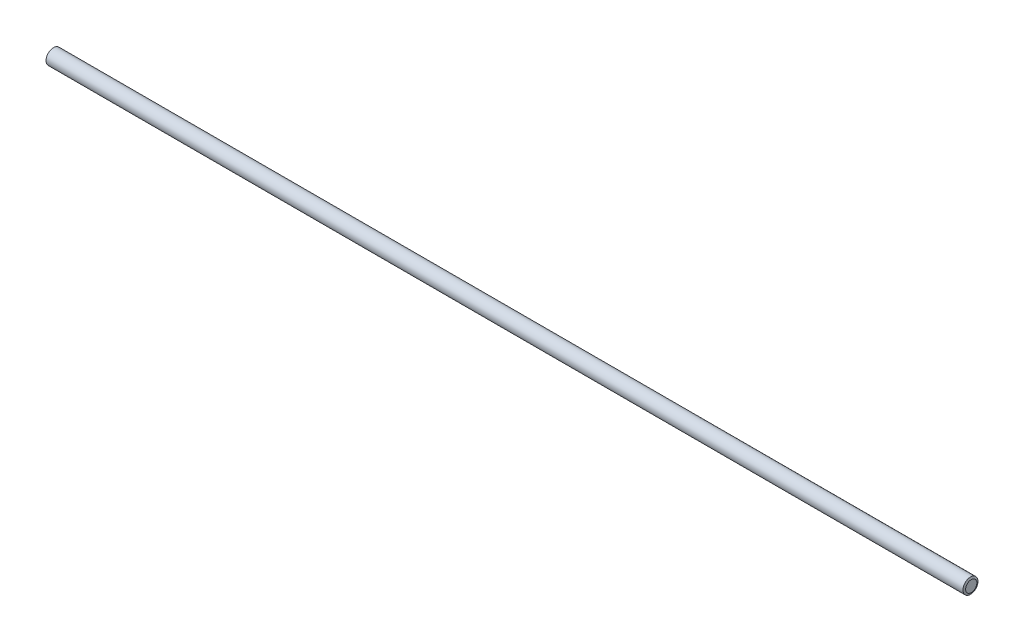
from build123d import *


with BuildPart() as part:
    # Sketch1 → Revolve1 (revolve)
    with BuildSketch(Plane.XY):
        Polygon((0, 0), (0, 3.736946), (0.5, 5), (609.5, 5), (610, 3.736946), (610, 0), align=None)
    revolve(axis=Axis((610, 0, 0), (-1, 0, 0)))


solid = part.part
